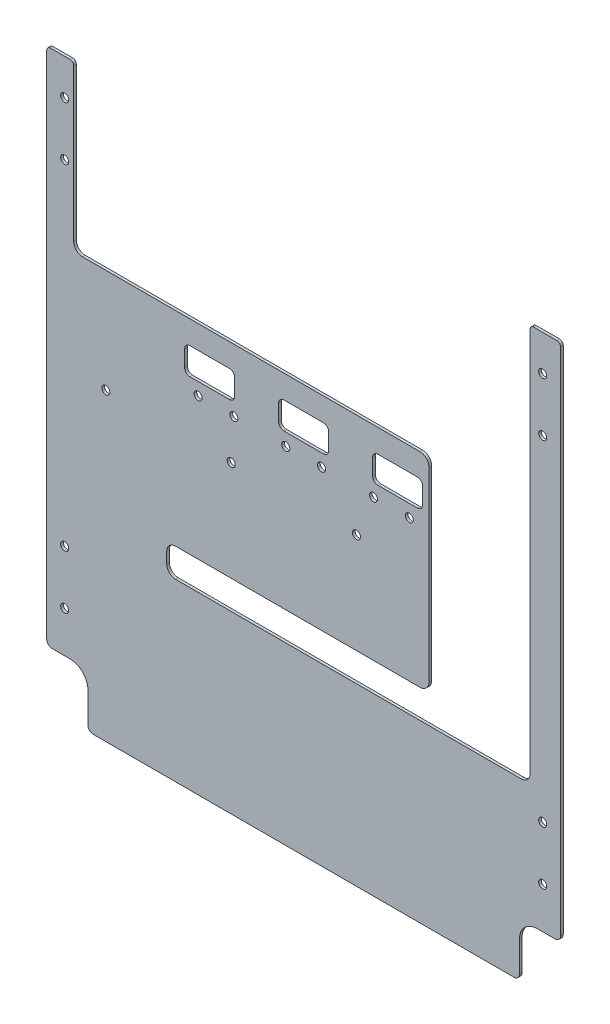
from build123d import *

# Parameters (mm, degrees)
ESQUISSE1_W                  = 287
ESQUISSE1_H                  = 320
BOSS_EXTRU_1_DEPTH           = 1.5
ESQUISSE2_W                  = 23
ESQUISSE2_H                  = 30
ENL_V_MAT_EXTRU_1_DEPTH      = 1
ENL_V_MAT_EXTRU_1_DEPTH_BACK = 2.5
CONG_1_R                     = 10
CONG_2_R                     = 3
ESQUISSE3_W                  = 140
ESQUISSE3_H                  = 92
ENL_V_MAT_EXTRU_2_DEPTH      = 1
ENL_V_MAT_EXTRU_2_DEPTH_BACK = 2.5
ESQUISSE4_W                  = 56.5
ESQUISSE4_H                  = 222
ENL_V_MAT_EXTRU_3_DEPTH      = 1
ENL_V_MAT_EXTRU_3_DEPTH_BACK = 2.5
ESQUISSE5_W                  = 58.5
ESQUISSE5_H                  = 92
ENL_V_MAT_EXTRU_4_DEPTH      = 1
ENL_V_MAT_EXTRU_4_DEPTH_BACK = 2.5
ESQUISSE6_W                  = 146.5
ESQUISSE6_H                  = 16
ENL_V_MAT_EXTRU_5_DEPTH      = 1
ENL_V_MAT_EXTRU_5_DEPTH_BACK = 2.5
CONG_3_R                     = 5
ESQUISSE7_R                  = 2.25
ENL_V_MAT_EXTRU_6_DEPTH      = 1
ENL_V_MAT_EXTRU_6_DEPTH_BACK = 2.5
ESQUISSE8_R                  = 2.25
ENL_V_MAT_EXTRU_7_DEPTH      = 1
ENL_V_MAT_EXTRU_7_DEPTH_BACK = 2.5
ESQUISSE9_W                  = 28
ESQUISSE9_H                  = 15
ENL_V_MAT_EXTRU_8_DEPTH      = 1
ENL_V_MAT_EXTRU_8_DEPTH_BACK = 2.5
CONG_4_R                     = 3
CONG_6_R                     = 2


with BuildPart() as part:
    # Esquisse1 → Boss.-Extru.1 (new body)
    with BuildSketch(Plane.XY):
        with Locations((143.5, 160)):
            Rectangle(ESQUISSE1_W, ESQUISSE1_H)
    extrude(amount=BOSS_EXTRU_1_DEPTH)

    # Esquisse2 → Enlèv. mat.-Extru.1 (cut, two sides)
    with BuildSketch(Plane.XY.offset(1.5)) as enl_v_mat_extru_1_sk:
        with Locations((275.5, 15)):
            Rectangle(ESQUISSE2_W, ESQUISSE2_H)
        with Locations((11.5, 15)):
            Rectangle(ESQUISSE2_W, ESQUISSE2_H)
    extrude(amount=ENL_V_MAT_EXTRU_1_DEPTH, mode=Mode.SUBTRACT)
    extrude(enl_v_mat_extru_1_sk.sketch, amount=-ENL_V_MAT_EXTRU_1_DEPTH_BACK, mode=Mode.SUBTRACT)

    # Congé1
    cong_1_edges = [part.edges().sort_by_distance(p)[0] for p in [
        (264, 30, 0.75),
        (23, 30, 0.75),
    ]]
    fillet(cong_1_edges, radius=CONG_1_R)

    # Congé2
    cong_2_edges = [part.edges().sort_by_distance(p)[0] for p in [
        (287, 30, 0.75),
        (264, 0, 0.75),
        (23, 0, 0.75),
        (0, 30, 0.75),
    ]]
    fillet(cong_2_edges, radius=CONG_2_R)

    # Esquisse3 → Enlèv. mat.-Extru.2 (cut, two sides)
    with BuildSketch(Plane.XY.offset(1.5)) as enl_v_mat_extru_2_sk:
        with Locations((143.5, 274)):
            Rectangle(ESQUISSE3_W, ESQUISSE3_H)
    extrude(amount=ENL_V_MAT_EXTRU_2_DEPTH, mode=Mode.SUBTRACT)
    extrude(enl_v_mat_extru_2_sk.sketch, amount=-ENL_V_MAT_EXTRU_2_DEPTH_BACK, mode=Mode.SUBTRACT)

    # Esquisse4 → Enlèv. mat.-Extru.3 (cut, two sides)
    with BuildSketch(Plane.XY.offset(1.5)) as enl_v_mat_extru_3_sk:
        with Locations((241.75, 209)):
            Rectangle(ESQUISSE4_W, ESQUISSE4_H)
    extrude(amount=ENL_V_MAT_EXTRU_3_DEPTH, mode=Mode.SUBTRACT)
    extrude(enl_v_mat_extru_3_sk.sketch, amount=-ENL_V_MAT_EXTRU_3_DEPTH_BACK, mode=Mode.SUBTRACT)

    # Esquisse5 → Enlèv. mat.-Extru.4 (cut, two sides)
    with BuildSketch(Plane.XY.offset(1.5)) as enl_v_mat_extru_4_sk:
        with Locations((44.25, 274)):
            Rectangle(ESQUISSE5_W, ESQUISSE5_H)
    extrude(amount=ENL_V_MAT_EXTRU_4_DEPTH, mode=Mode.SUBTRACT)
    extrude(enl_v_mat_extru_4_sk.sketch, amount=-ENL_V_MAT_EXTRU_4_DEPTH_BACK, mode=Mode.SUBTRACT)

    # Esquisse6 → Enlèv. mat.-Extru.5 (cut, two sides)
    with BuildSketch(Plane.XY.offset(1.5)) as enl_v_mat_extru_5_sk:
        with Locations((140.25, 106)):
            Rectangle(ESQUISSE6_W, ESQUISSE6_H)
    extrude(amount=ENL_V_MAT_EXTRU_5_DEPTH, mode=Mode.SUBTRACT)
    extrude(enl_v_mat_extru_5_sk.sketch, amount=-ENL_V_MAT_EXTRU_5_DEPTH_BACK, mode=Mode.SUBTRACT)

    # Congé3
    cong_3_edges = [part.edges().sort_by_distance(p)[0] for p in [
        (270, 98, 0.75),
        (15, 228, 0.75),
        (67, 98, 0.75),
        (213.5, 114, 0.75),
        (67, 114, 0.75),
        (213.5, 228, 0.75),
    ]]
    fillet(cong_3_edges, radius=CONG_3_R)

    # Esquisse7 → Enlèv. mat.-Extru.6 (cut, two sides)
    with BuildSketch(Plane.XY.offset(1.5)) as enl_v_mat_extru_6_sk:
        with Locations((277, 300)):
            Circle(ESQUISSE7_R)
        with Locations((277, 270)):
            Circle(ESQUISSE7_R)
        with Locations((10, 270)):
            Circle(ESQUISSE7_R)
        with Locations((10, 300)):
            Circle(ESQUISSE7_R)
        with Locations((277, 83)):
            Circle(ESQUISSE7_R)
        with Locations((277, 53)):
            Circle(ESQUISSE7_R)
        with Locations((10, 53)):
            Circle(ESQUISSE7_R)
        with Locations((10, 83)):
            Circle(ESQUISSE7_R)
        with Locations((33, 170)):
            Circle(ESQUISSE7_R)
        with Locations((103, 170)):
            Circle(ESQUISSE7_R)
        with Locations((173, 170)):
            Circle(ESQUISSE7_R)
    extrude(amount=ENL_V_MAT_EXTRU_6_DEPTH, mode=Mode.SUBTRACT)
    extrude(enl_v_mat_extru_6_sk.sketch, amount=-ENL_V_MAT_EXTRU_6_DEPTH_BACK, mode=Mode.SUBTRACT)

    # Esquisse8 → Enlèv. mat.-Extru.7 (cut, two sides)
    with BuildSketch(Plane.XY.offset(1.5)) as enl_v_mat_extru_7_sk:
        with Locations((133.5, 193)):
            Circle(ESQUISSE8_R)
        with Locations((153.5, 193)):
            Circle(ESQUISSE8_R)
        with Locations((182.5, 193)):
            Circle(ESQUISSE8_R)
        with Locations((202.5, 193)):
            Circle(ESQUISSE8_R)
        with Locations((84.5, 193)):
            Circle(ESQUISSE8_R)
        with Locations((104.5, 193)):
            Circle(ESQUISSE8_R)
    extrude(amount=ENL_V_MAT_EXTRU_7_DEPTH, mode=Mode.SUBTRACT)
    extrude(enl_v_mat_extru_7_sk.sketch, amount=-ENL_V_MAT_EXTRU_7_DEPTH_BACK, mode=Mode.SUBTRACT)

    # Esquisse9 → Enlèv. mat.-Extru.8 (cut, two sides)
    with BuildSketch(Plane.XY.offset(1.5)) as enl_v_mat_extru_8_sk:
        with Locations((143.5, 207.5)):
            Rectangle(ESQUISSE9_W, ESQUISSE9_H)
        with Locations((196, 207.5)):
            Rectangle(ESQUISSE9_W, ESQUISSE9_H)
        with Locations((91, 207.5)):
            Rectangle(ESQUISSE9_W, ESQUISSE9_H)
    extrude(amount=ENL_V_MAT_EXTRU_8_DEPTH, mode=Mode.SUBTRACT)
    extrude(enl_v_mat_extru_8_sk.sketch, amount=-ENL_V_MAT_EXTRU_8_DEPTH_BACK, mode=Mode.SUBTRACT)

    # Congé4
    cong_4_edges = [part.edges().sort_by_distance(p)[0] for p in [
        (129.5, 200, 0.75),
        (129.5, 215, 0.75),
        (157.5, 215, 0.75),
        (157.5, 200, 0.75),
        (182, 215, 0.75),
        (210, 215, 0.75),
        (210, 200, 0.75),
        (182, 200, 0.75),
        (77, 200, 0.75),
        (77, 215, 0.75),
        (105, 215, 0.75),
        (105, 200, 0.75),
    ]]
    fillet(cong_4_edges, radius=CONG_4_R)

    # Congé6
    cong_6_edges = [part.edges().sort_by_distance(p)[0] for p in [
        (270, 320, 0.75),
        (15, 320, 0.75),
        (0, 320, 0.75),
        (287, 320, 0.75),
    ]]
    fillet(cong_6_edges, radius=CONG_6_R)


solid = part.part
